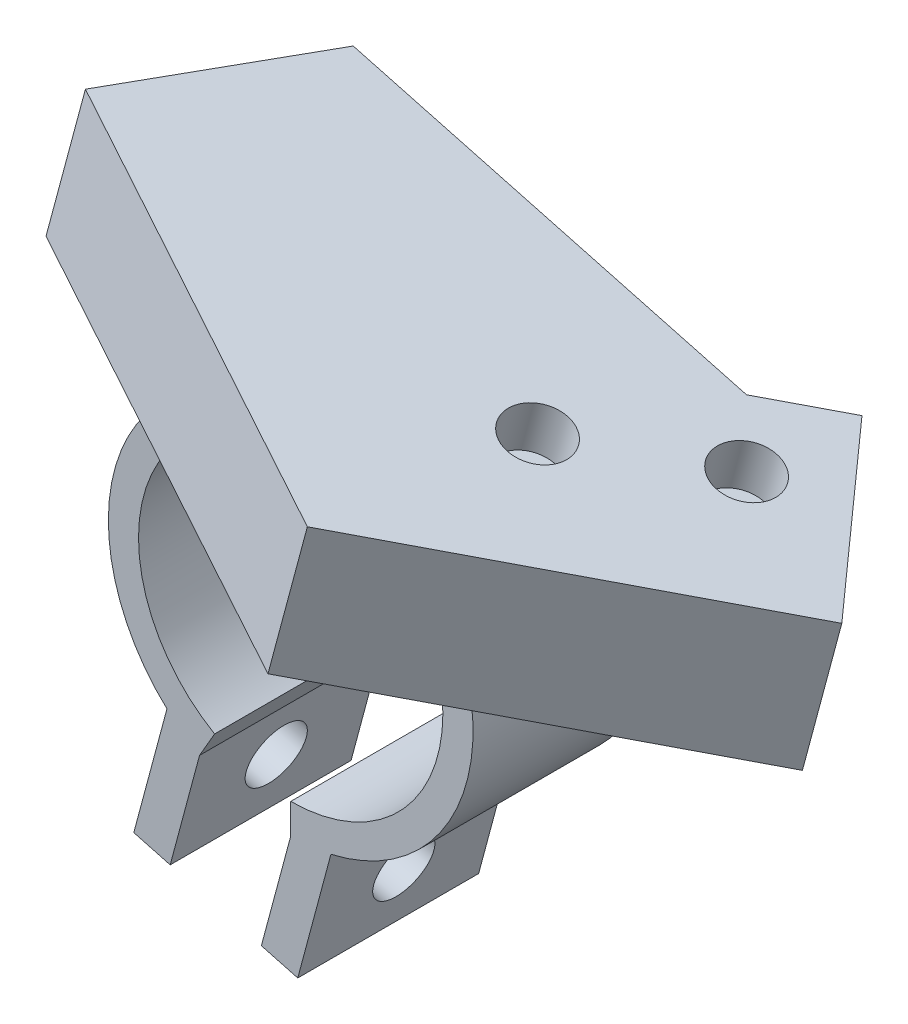
from build123d import *

# Parameters (mm, degrees)
SKETCH1_R                = 24.193
SKETCH1_R_2              = 20.193
BOSS_EXTRUDE1_DEPTH      = 24
CUT_EXTRUDE1_DEPTH       = 24
BOSS_EXTRUDE2_START      = -24
BOSS_EXTRUDE2_DEPTH      = 24
CUT_EXTRUDE2_DEPTH       = 24
BOSS_EXTRUDE3_DEPTH      = 9.2
BOSS_EXTRUDE3_DEPTH_BACK = 11
SKETCH6_R                = 4
CUT_EXTRUDE4_START       = -4.5
SKETCH6_5_R              = 4
CUT_EXTRUDE4_DEPTH       = 4.5


with BuildPart() as part:
    # Sketch1 → Boss-Extrude1 (new body)
    with BuildSketch(Plane.XY):
        Circle(SKETCH1_R)
        Circle(SKETCH1_R_2, mode=Mode.SUBTRACT)
    extrude(amount=BOSS_EXTRUDE1_DEPTH)

    # Sketch2 → Cut-Extrude1 (cut)
    with BuildSketch(Plane.XY.offset(24)):
        Polygon((0, -24.193), (-5.8341998, -24.895299835), (-12.0965, -20.951752594), (0, 0), align=None)
    extrude(amount=-CUT_EXTRUDE1_DEPTH, mode=Mode.SUBTRACT)

    # Sketch3 → Boss-Extrude2 (add)
    with BuildSketch(Plane.XY.offset(24).offset(BOSS_EXTRUDE2_START)):
        with BuildLine():
            Line((-15.990029306, -35.482601784), (-12.0965, -20.951752594))
            ThreePointArc((-12.0965, -20.951752594), (-14.346719144, -19.480064138), (-16.419734671, -17.767767512))
            Line((-16.419734671, -17.767767512), (-20.819658437, -34.188506559))
            Line((-20.819658437, -34.188506559), (-15.990029306, -35.482601784))
        make_face()
        with BuildLine():
            ThreePointArc((5.336023592, -23.597205369), (2.684591171, -24.043589982), (0, -24.193))
            Line((0, -24.193), (-3.893529306, -38.72384919))
            Line((-3.893529306, -38.72384919), (0.936099826, -40.017944416))
            Line((0.936099826, -40.017944416), (5.336023592, -23.597205369))
        make_face()
    extrude(amount=BOSS_EXTRUDE2_DEPTH)

    # Sketch4 → Cut-Extrude2 (cut)
    with BuildSketch(Plane(origin=(-10.877879131, 2.914718929, 0), x_dir=(0, 0, 1), z_dir=(-0.9659258262890682, 0.2588190451025212, 0))):
        with BuildLine():
            ThreePointArc((12, -34.412085563), (14.828427125, -33.240512688), (16, -30.412085563))
            ThreePointArc((16, -30.412085563), (9.171572875, -27.583658439), (12, -34.412085563))
        make_face()
    extrude(amount=-CUT_EXTRUDE2_DEPTH, mode=Mode.SUBTRACT)

    # Sketch6 → Boss-Extrude3 (add, two sides: drawn at the far end of the back side and taken through both)
    with BuildSketch(Plane(origin=(7.790062397, 29.072908658, 0), x_dir=(0.9659258262890688, -0.2588190451025194, 0), z_dir=(-0.2588190451025194, -0.9659258262890688, 0)).offset(-BOSS_EXTRUDE3_DEPTH_BACK)):
        Polygon((-27.270593421, 0), (26.757277212, 0), (34.96828798, -7.387146438), (53.361016662, 13.056863238), (15.35042048, 47.253608089), (-37.726339728, 25.434766937), align=None)
        with Locations((33.971441151, 6.96105325)):
            Circle(SKETCH6_R, mode=Mode.SUBTRACT)
        with Locations((19.103070478, 20.337583201)):
            Circle(SKETCH6_R, mode=Mode.SUBTRACT)
    extrude(amount=BOSS_EXTRUDE3_DEPTH + BOSS_EXTRUDE3_DEPTH_BACK)

    # Sketch6_5 → Cut-Extrude4 (cut)
    with BuildSketch(Plane(origin=(7.790062397, 29.072908658, 0), x_dir=(0.9659258262890688, -0.2588190451025194, 0), z_dir=(-0.2588190451025194, -0.9659258262890688, 0)).offset(CUT_EXTRUDE4_START)):
        Polygon((-34.874772554, 18.498012318), (-27.270593421, 0), (26.757277212, 0), (34.96828798, -7.387146438), (48.34481793, 7.481224235), (13.840171432, 38.52379423), align=None)
        with Locations((33.971441151, 6.96105325)):
            Circle(SKETCH6_5_R, mode=Mode.SUBTRACT)
        with Locations((19.103070478, 20.337583201)):
            Circle(SKETCH6_5_R, mode=Mode.SUBTRACT)
    extrude(amount=CUT_EXTRUDE4_DEPTH, mode=Mode.SUBTRACT)


solid = part.part
